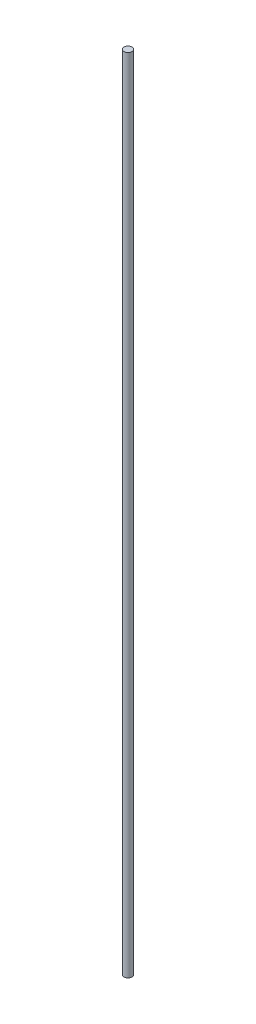
from build123d import *

# Parameters (mm, degrees)
SKETCH_1_R      = 1
EXTRUDE_1_DEPTH = 200


with BuildPart() as part:
    # 草图1 → 凸台-拉伸1 (new body)
    with BuildSketch(Plane(origin=(0, 0, 0), x_dir=(1, 0, 0), z_dir=(0, 1, 0))):
        Circle(SKETCH_1_R)
    extrude(amount=EXTRUDE_1_DEPTH)


solid = part.part
